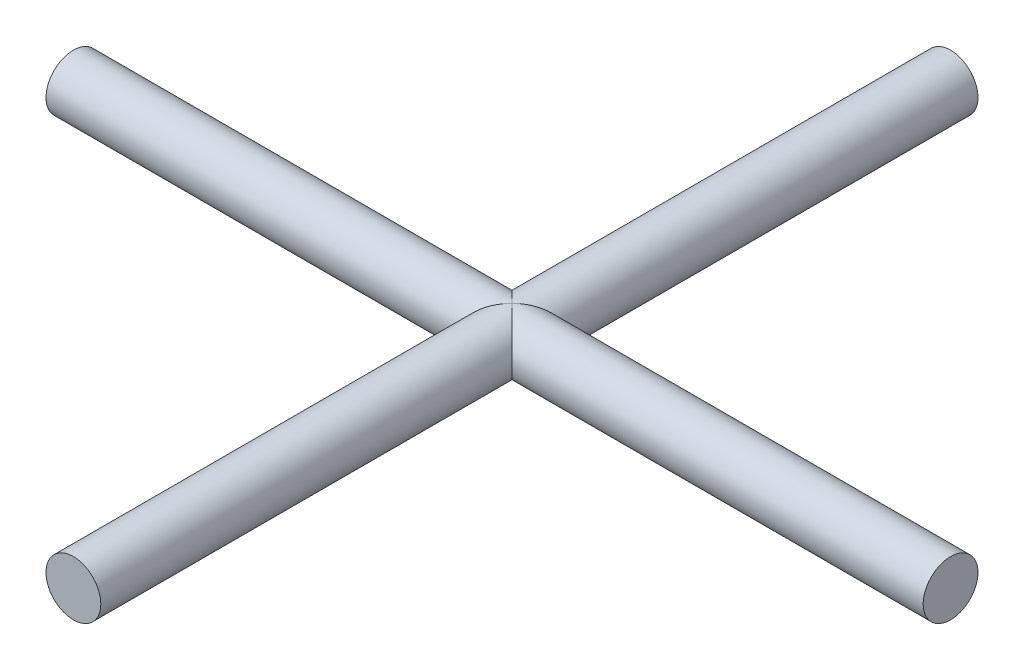
from build123d import *

# Parameters (mm, degrees)
SKETCH4_R           = 2.5
BOSS_EXTRUDE3_DEPTH = 40
SKETCH5_R           = 2.5
BOSS_EXTRUDE4_DEPTH = 40


with BuildPart() as part:
    # Sketch4 → Boss-Extrude3 (new body, symmetric)
    with BuildSketch(Plane.XY):
        Circle(SKETCH4_R)
    extrude(amount=BOSS_EXTRUDE3_DEPTH, both=True)

    # Sketch5 → Boss-Extrude4 (add, symmetric)
    with BuildSketch(Plane(origin=(0, 0, 0), x_dir=(0, 0, -1), z_dir=(1, 0, 0))):
        Circle(SKETCH5_R)
    extrude(amount=BOSS_EXTRUDE4_DEPTH, both=True)


solid = part.part
